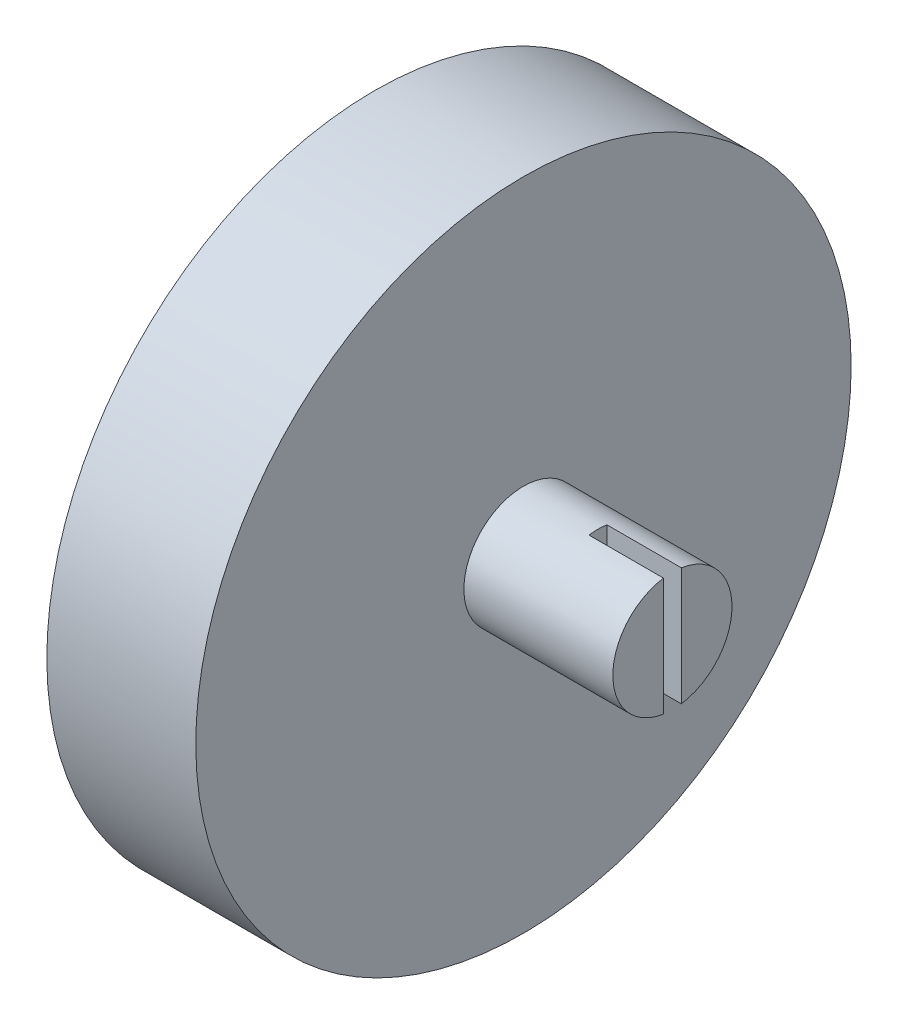
from build123d import *

# Parameters (mm, degrees)
SKETCH1_R           = 22
BOSS_EXTRUDE1_DEPTH = 10
CUT_EXTRUDE2_DEPTH  = 5.5
SKETCH15_W          = 18
SKETCH15_H          = 24.118038922
CUT_EXTRUDE3_DEPTH  = 3
SKETCH16_R          = 4
BOSS_EXTRUDE2_DEPTH = 10
CUT_EXTRUDE4_START  = 20
SKETCH8_W           = 1.2
SKETCH8_H           = 10
CUT_EXTRUDE4_DEPTH  = 5
SKETCH17_W          = 4
SKETCH17_H          = 1.75
BOSS_EXTRUDE3_DEPTH = 1
SKETCH18_W          = 4.25
SKETCH18_H          = 1.737607108
BOSS_EXTRUDE4_DEPTH = 1
SKETCH22_R          = 1.5
CUT_EXTRUDE7_DEPTH  = 7


with BuildPart() as part:
    # Sketch1 → Boss-Extrude1 (new body)
    with BuildSketch(Plane(origin=(0, 0, 0), x_dir=(0, 0, -1), z_dir=(1, 0, 0))):
        Circle(SKETCH1_R)
    extrude(amount=BOSS_EXTRUDE1_DEPTH)

    # Sketch13 → Cut-Extrude2 (cut)
    with BuildSketch(Plane(origin=(0, 0, 0), x_dir=(0, 0, -1), z_dir=(1, 0, 0))):
        with BuildLine():
            Line((-2.670420152, -16.85816067), (-2.670420152, -16.530371213))
            Line((-2.670420152, -16.530371213), (-4.762392892, -10))
            Line((-4.762392892, -10), (-4.762392892, -6.943148259))
            Line((-4.762392892, -6.943148259), (-6.5, -6.943148259))
            Line((-6.5, -6.943148259), (-6.5, 19.556851741))
            Line((-6.5, 19.556851741), (6.5, 19.556851741))
            Line((6.5, 19.556851741), (6.5, -6.943148259))
            Line((6.5, -6.943148259), (4.762392892, -6.943148259))
            Line((4.762392892, -6.943148259), (4.762392892, -10))
            Line((4.762392892, -10), (2.670420152, -16.530371213))
            Line((2.670420152, -16.530371213), (2.670420152, -16.85816067))
            Line((2.670420152, -16.85816067), (2.670420152, -21.837327131))
            ThreePointArc((2.670420152, -21.837327131), (1.836835043, -21.92318492), (1.000584871, -21.977234355))
            Line((1.000584871, -21.977234355), (0, -25.25))
            Line((0, -25.25), (-1.000584871, -21.977234355))
            ThreePointArc((-1.000584871, -21.977234355), (-1.836835043, -21.92318492), (-2.670420152, -21.837327131))
            Line((-2.670420152, -21.837327131), (-2.670420152, -16.85816067))
        make_face()
    extrude(amount=CUT_EXTRUDE2_DEPTH, mode=Mode.SUBTRACT)

    # Sketch15 → Cut-Extrude3 (cut)
    with BuildSketch(Plane.ZY):
        with Locations((0, 5.115871202)):
            Rectangle(SKETCH15_W, SKETCH15_H)
    extrude(amount=-CUT_EXTRUDE3_DEPTH, mode=Mode.SUBTRACT)

    # Sketch16 → Boss-Extrude2 (add)
    with BuildSketch(Plane(origin=(10, 0, 0), x_dir=(0, 0, -1), z_dir=(1, 0, 0))):
        Circle(SKETCH16_R)
    extrude(amount=BOSS_EXTRUDE2_DEPTH)

    # Sketch8 → Cut-Extrude4 (cut)
    with BuildSketch(Plane(origin=(0, 0, 0), x_dir=(0, 0, -1), z_dir=(1, 0, 0)).offset(CUT_EXTRUDE4_START)):
        Rectangle(SKETCH8_W, SKETCH8_H)
    extrude(amount=-CUT_EXTRUDE4_DEPTH, mode=Mode.SUBTRACT)

    # Sketch17 → Boss-Extrude3 (add)
    with BuildSketch(Plane(origin=(0, -6.943148259, 0), x_dir=(1, 0, 0), z_dir=(0, 1, 0))):
        with Locations((2, 5.637392892)):
            Rectangle(SKETCH17_W, SKETCH17_H)
    extrude(amount=BOSS_EXTRUDE3_DEPTH)

    # Sketch18 → Boss-Extrude4 (add)
    with BuildSketch(Plane(origin=(0, -6.943148259, 0), x_dir=(1, 0, 0), z_dir=(0, 1, 0))):
        with Locations((2.125, -5.631196446)):
            Rectangle(SKETCH18_W, SKETCH18_H)
    extrude(amount=BOSS_EXTRUDE4_DEPTH)

    # Sketch22 → Cut-Extrude7 (cut)
    with BuildSketch(Plane(origin=(0, 0, 0), x_dir=(0, 0, -1), z_dir=(1, 0, 0))):
        with Locations((-14, 0)):
            Circle(SKETCH22_R)
        with Locations((14, 0)):
            Circle(SKETCH22_R)
    extrude(amount=CUT_EXTRUDE7_DEPTH, mode=Mode.SUBTRACT)


solid = part.part
